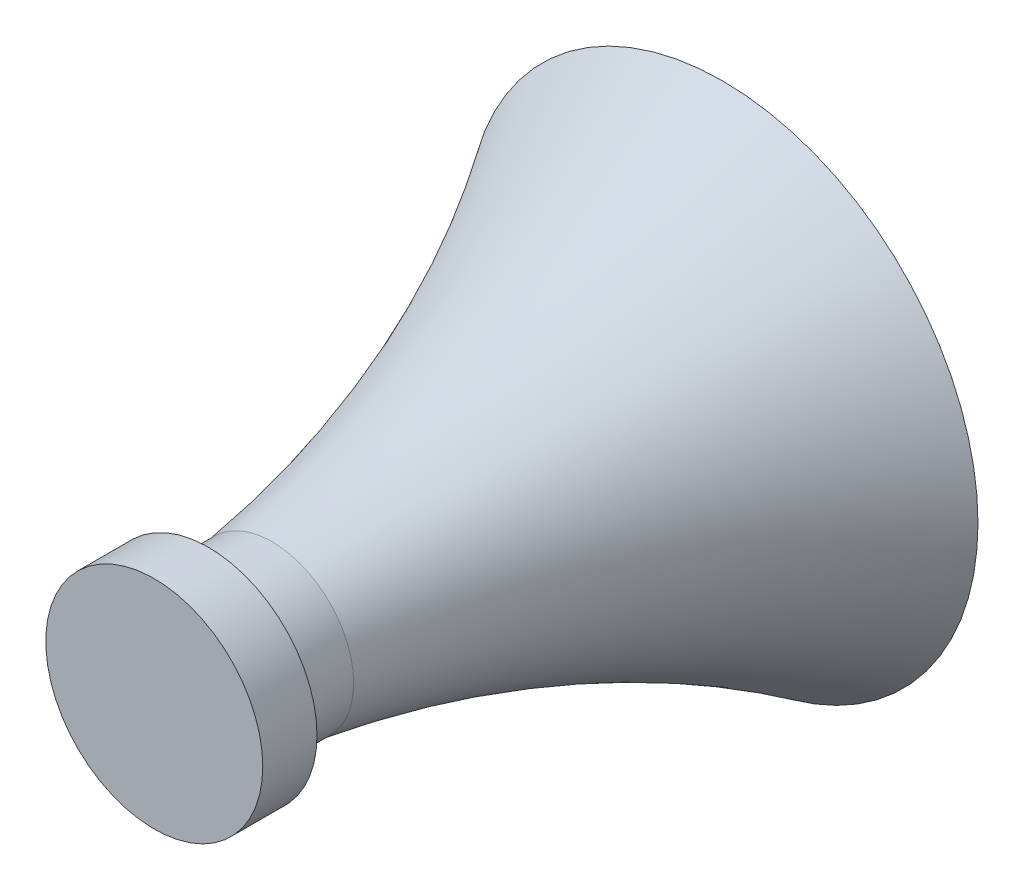
from build123d import *


with BuildPart() as part:
    # Sketch1 → Revolve2 (revolve)
    with BuildSketch(Plane(origin=(0, 0, 0), x_dir=(1, 0, 0), z_dir=(0, 1, 0))):
        with BuildLine():
            ThreePointArc((9.415562128, 18.954471585), (5.262334896, 11.015891219), (3.004951609, 2.345563927))
            Line((3.004951609, 2.345563927), (3.004951609, 0))
            Line((3.004951609, 0), (4, 0))
            Line((4, 0), (4, -2))
            Line((4, -2), (0, -2))
            Line((0, -2), (0, 0))
            Line((0, 0), (0, 10))
            Line((0, 10), (0.75, 10))
            ThreePointArc((0.75, 10), (1.788096318, 6.210069956), (2.5, 2.345563927))
            ThreePointArc((2.5, 2.345563927), (4.722740089, 11.005000833), (8.813257881, 18.954471585))
            Line((8.813257881, 18.954471585), (9.415562128, 18.954471585))
        make_face()
    revolve(axis=Axis((0, 0, 2), (0, 0, -1)))


solid = part.part
